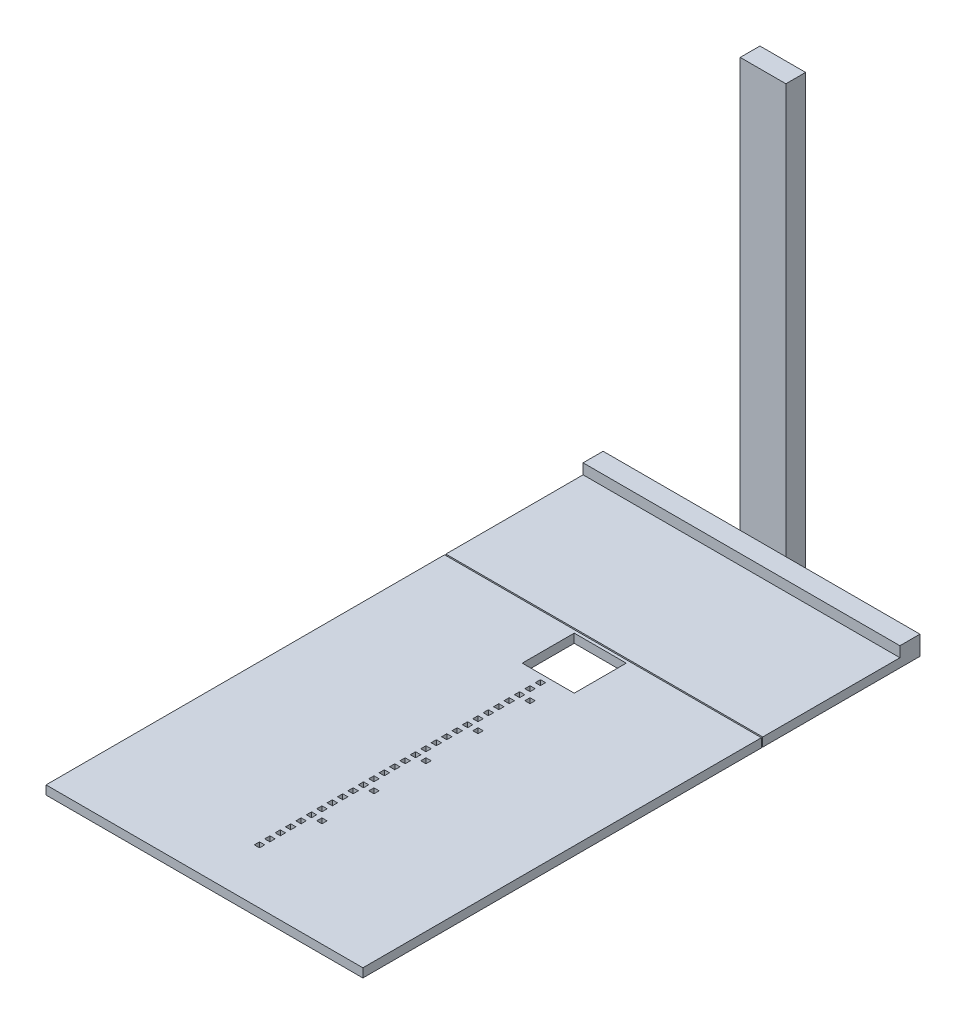
from build123d import *

# Parameters (mm, degrees)
SKETCH1_W           = 609
SKETCH1_H           = 766
SKETCH1_W_2         = 10
SKETCH1_H_2         = 10
SKETCH1_W_3         = 100
SKETCH1_H_3         = 100
BOSS_EXTRUDE1_DEPTH = 17
SKETCH2_W           = 609
SKETCH2_H           = 302.26
BOSS_EXTRUDE2_DEPTH = 17
SKETCH3_W           = 609
SKETCH3_H           = 38.5
BOSS_EXTRUDE3_DEPTH = 20
SKETCH4_W           = 87.8
SKETCH4_H           = 37.9
BOSS_EXTRUDE4_DEPTH = 824.4


with BuildPart() as part:
    # Sketch1 → Boss-Extrude1 (new body)
    with BuildSketch(Plane(origin=(0, 0, 0), x_dir=(1, 0, 0), z_dir=(0, 1, 0))):
        with Locations((-0.5, -327.27)):
            Rectangle(SKETCH1_W, SKETCH1_H)
        with Locations((0, -85)):
            Rectangle(SKETCH1_W_2, SKETCH1_H_2, mode=Mode.SUBTRACT)
        Rectangle(SKETCH1_W_3, SKETCH1_H_3, mode=Mode.SUBTRACT)
        with Locations((0, -65)):
            Rectangle(SKETCH1_W_2, SKETCH1_H_2, mode=Mode.SUBTRACT)
        with Locations((0, -105)):
            Rectangle(SKETCH1_W_2, SKETCH1_H_2, mode=Mode.SUBTRACT)
        with Locations((0, -125)):
            Rectangle(SKETCH1_W_2, SKETCH1_H_2, mode=Mode.SUBTRACT)
        with Locations((0, -145)):
            Rectangle(SKETCH1_W_2, SKETCH1_H_2, mode=Mode.SUBTRACT)
        with Locations((0, -165)):
            Rectangle(SKETCH1_W_2, SKETCH1_H_2, mode=Mode.SUBTRACT)
        with Locations((0, -185)):
            Rectangle(SKETCH1_W_2, SKETCH1_H_2, mode=Mode.SUBTRACT)
        with Locations((0, -205)):
            Rectangle(SKETCH1_W_2, SKETCH1_H_2, mode=Mode.SUBTRACT)
        with Locations((0, -225)):
            Rectangle(SKETCH1_W_2, SKETCH1_H_2, mode=Mode.SUBTRACT)
        with Locations((0, -245)):
            Rectangle(SKETCH1_W_2, SKETCH1_H_2, mode=Mode.SUBTRACT)
        with Locations((0, -265)):
            Rectangle(SKETCH1_W_2, SKETCH1_H_2, mode=Mode.SUBTRACT)
        with Locations((0, -285)):
            Rectangle(SKETCH1_W_2, SKETCH1_H_2, mode=Mode.SUBTRACT)
        with Locations((0, -305)):
            Rectangle(SKETCH1_W_2, SKETCH1_H_2, mode=Mode.SUBTRACT)
        with Locations((0, -325)):
            Rectangle(SKETCH1_W_2, SKETCH1_H_2, mode=Mode.SUBTRACT)
        with Locations((0, -345)):
            Rectangle(SKETCH1_W_2, SKETCH1_H_2, mode=Mode.SUBTRACT)
        with Locations((0, -365)):
            Rectangle(SKETCH1_W_2, SKETCH1_H_2, mode=Mode.SUBTRACT)
        with Locations((0, -385)):
            Rectangle(SKETCH1_W_2, SKETCH1_H_2, mode=Mode.SUBTRACT)
        with Locations((0, -405)):
            Rectangle(SKETCH1_W_2, SKETCH1_H_2, mode=Mode.SUBTRACT)
        with Locations((0, -425)):
            Rectangle(SKETCH1_W_2, SKETCH1_H_2, mode=Mode.SUBTRACT)
        with Locations((0, -445)):
            Rectangle(SKETCH1_W_2, SKETCH1_H_2, mode=Mode.SUBTRACT)
        with Locations((0, -465)):
            Rectangle(SKETCH1_W_2, SKETCH1_H_2, mode=Mode.SUBTRACT)
        with Locations((0, -485)):
            Rectangle(SKETCH1_W_2, SKETCH1_H_2, mode=Mode.SUBTRACT)
        with Locations((0, -505)):
            Rectangle(SKETCH1_W_2, SKETCH1_H_2, mode=Mode.SUBTRACT)
        with Locations((0, -525)):
            Rectangle(SKETCH1_W_2, SKETCH1_H_2, mode=Mode.SUBTRACT)
        with Locations((0, -545)):
            Rectangle(SKETCH1_W_2, SKETCH1_H_2, mode=Mode.SUBTRACT)
        with Locations((0, -565)):
            Rectangle(SKETCH1_W_2, SKETCH1_H_2, mode=Mode.SUBTRACT)
        with Locations((0, -585)):
            Rectangle(SKETCH1_W_2, SKETCH1_H_2, mode=Mode.SUBTRACT)
        with Locations((0, -605)):
            Rectangle(SKETCH1_W_2, SKETCH1_H_2, mode=Mode.SUBTRACT)
        with Locations((20, -105)):
            Rectangle(SKETCH1_W_2, SKETCH1_H_2, mode=Mode.SUBTRACT)
        with Locations((20, -205)):
            Rectangle(SKETCH1_W_2, SKETCH1_H_2, mode=Mode.SUBTRACT)
        with Locations((20, -305)):
            Rectangle(SKETCH1_W_2, SKETCH1_H_2, mode=Mode.SUBTRACT)
        with Locations((20, -405)):
            Rectangle(SKETCH1_W_2, SKETCH1_H_2, mode=Mode.SUBTRACT)
        with Locations((20, -505)):
            Rectangle(SKETCH1_W_2, SKETCH1_H_2, mode=Mode.SUBTRACT)
    extrude(amount=BOSS_EXTRUDE1_DEPTH)


with BuildPart() as body_2:
    # Sketch2 → Boss-Extrude2 (new body)
    with BuildSketch(Plane(origin=(0, 0, 0), x_dir=(-1, 0, 0), z_dir=(0, -1, 0))):
        with Locations((0.5, 209.4)):
            Rectangle(SKETCH2_W, SKETCH2_H)
    extrude(amount=-BOSS_EXTRUDE2_DEPTH)

    # Sketch3 → Boss-Extrude3 (add)
    with BuildSketch(Plane(origin=(0, 17, 0), x_dir=(1, 0, 0), z_dir=(0, 1, 0))):
        with Locations((-0.5, 341.28)):
            Rectangle(SKETCH3_W, SKETCH3_H)
    extrude(amount=BOSS_EXTRUDE3_DEPTH)

    # Sketch4 → Boss-Extrude4 (add)
    with BuildSketch(Plane.XZ):
        with Locations((2.425, -379.48)):
            Rectangle(SKETCH4_W, SKETCH4_H)
    extrude(amount=-BOSS_EXTRUDE4_DEPTH)


solid = Compound([part.part, body_2.part])
